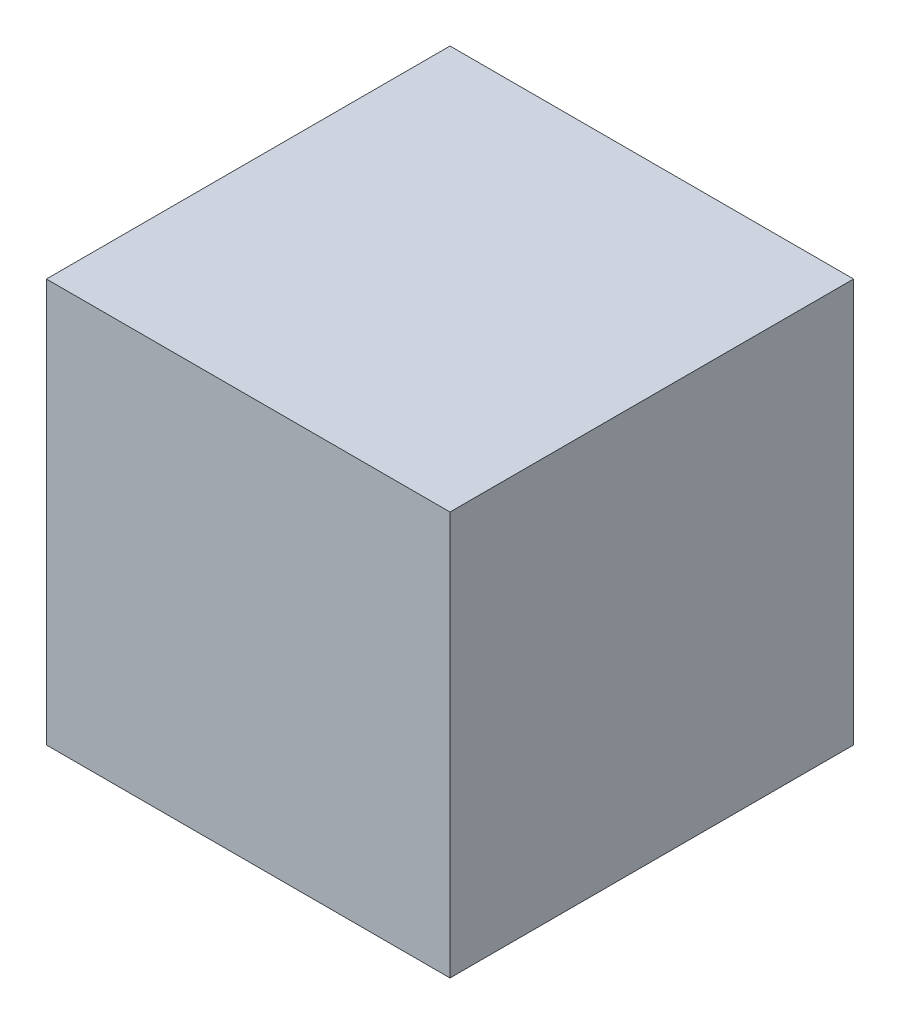
from build123d import *

# Parameters (mm, degrees)
SKETCH3_W           = 19.05
SKETCH3_H           = 19.05
BOSS_EXTRUDE1_DEPTH = 19.05


with BuildPart() as part:
    # Sketch3 → Boss-Extrude1 (new body)
    with BuildSketch(Plane(origin=(0, 0, 0), x_dir=(1, 0, 0), z_dir=(0, 1, 0))):
        with Locations((-9.525, 9.525)):
            Rectangle(SKETCH3_W, SKETCH3_H)
    extrude(amount=BOSS_EXTRUDE1_DEPTH)


solid = part.part
